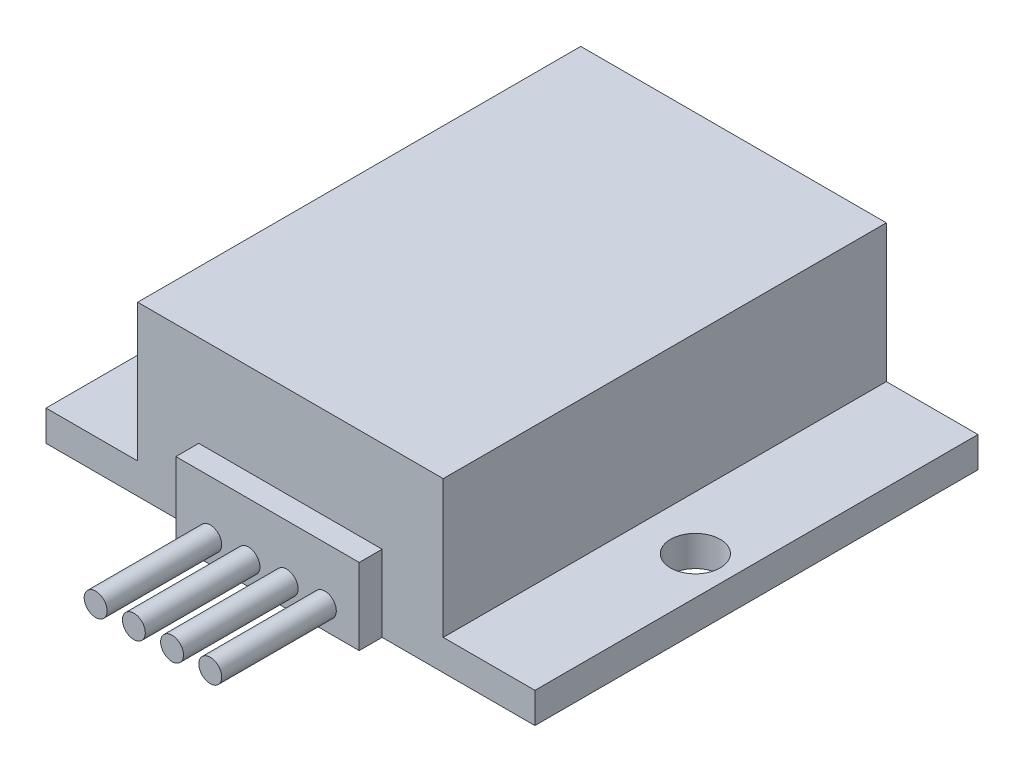
from build123d import *

# Parameters (mm, degrees)
SKETCH1_W             = 12
SKETCH1_H             = 58
SKETCH1_R             = 3.25
BOSS_EXTRUDE1_DEPTH   = 4
BOSS_EXTRUDE1_2_DEPTH = 4
BOSS_EXTRUDE2_DEPTH   = 22
SKETCH1_4_W           = 24
SKETCH1_4_H           = 3
BOSS_EXTRUDE3_DEPTH   = 10
SKETCH2_R             = 1.5
BOSS_EXTRUDE4_DEPTH   = 15


with BuildPart() as part:
    # Sketch1 → Boss-Extrude1 (new body)
    with BuildSketch(Plane(origin=(0, 0, 0), x_dir=(1, 0, 0), z_dir=(0, 1, 0))):
        with Locations((-26, 0)):
            Rectangle(SKETCH1_W, SKETCH1_H)
        with Locations((-27, -3)):
            Circle(SKETCH1_R, mode=Mode.SUBTRACT)
    extrude(amount=BOSS_EXTRUDE1_DEPTH)



with BuildPart() as body_2:
    # Sketch1 → Boss-Extrude1 2 (new body)
    with BuildSketch(Plane(origin=(0, 0, 0), x_dir=(1, 0, 0), z_dir=(0, 1, 0))):
        with Locations((26, 0)):
            Rectangle(SKETCH1_W, SKETCH1_H)
        with Locations((27, -3)):
            Circle(SKETCH1_R, mode=Mode.SUBTRACT)
    extrude(amount=BOSS_EXTRUDE1_2_DEPTH)


with BuildPart() as part_1:
    add(part.part)

    add(body_2.part)  # Boss-Extrude2 merges body 2
    # Sketch1_3 → Boss-Extrude2 (add)
    with BuildSketch(Plane(origin=(0, 0, 0), x_dir=(1, 0, 0), z_dir=(0, 1, 0))):
        Polygon((20, 29), (-20, 29), (-20, -29), (-12, -29), (12, -29), (20, -29), align=None)
    extrude(amount=BOSS_EXTRUDE2_DEPTH)

    # Sketch1_4 → Boss-Extrude3 (add)
    with BuildSketch(Plane(origin=(0, 0, 0), x_dir=(1, 0, 0), z_dir=(0, 1, 0))):
        with Locations((0, -30.5)):
            Rectangle(SKETCH1_4_W, SKETCH1_4_H)
    extrude(amount=BOSS_EXTRUDE3_DEPTH)

    # Sketch2 → Boss-Extrude4 (add)
    with BuildSketch(Plane.XY.offset(32)):
        with Locations((-7.5, 3)):
            Circle(SKETCH2_R)
        with Locations((-2.5, 3)):
            Circle(SKETCH2_R)
        with Locations((2.5, 3)):
            Circle(SKETCH2_R)
        with Locations((7.5, 3)):
            Circle(SKETCH2_R)
    extrude(amount=BOSS_EXTRUDE4_DEPTH)


solid = part_1.part
